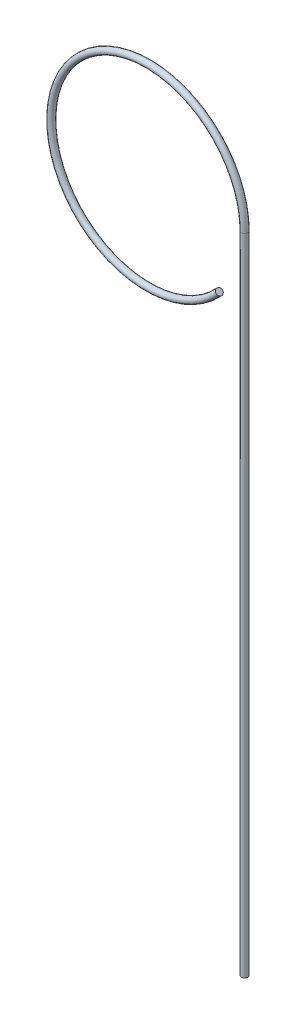
from build123d import *

# Parameters (mm, degrees)
SKETCH3_R           = 1
SKETCH4_R           = 1
BOSS_EXTRUDE1_DEPTH = 100


with BuildPart() as part:
    # Sweep2: sweep along a path in Sketch1
    with BuildLine(Plane.XY) as sweep2_path:
        Line((30, -100), (30, 0))
        ThreePointArc((30, 0), (-27.964255202, 10.862800329), (22.133304601, -20.251341373))
    # Sketch3 → Sweep2 (sweep)
    with BuildSketch(Plane(origin=(0, -100, 0), x_dir=(1, 0, 0), z_dir=(0, 1, 0))):
        with Locations((30, 0)):
            Circle(SKETCH3_R)
    sweep(path=sweep2_path.line)

    # Sketch4 → Boss-Extrude1 (add)
    with BuildSketch(Plane.XZ.offset(100)):
        with Locations((30, 0)):
            Circle(SKETCH4_R)
    extrude(amount=BOSS_EXTRUDE1_DEPTH)


solid = part.part
